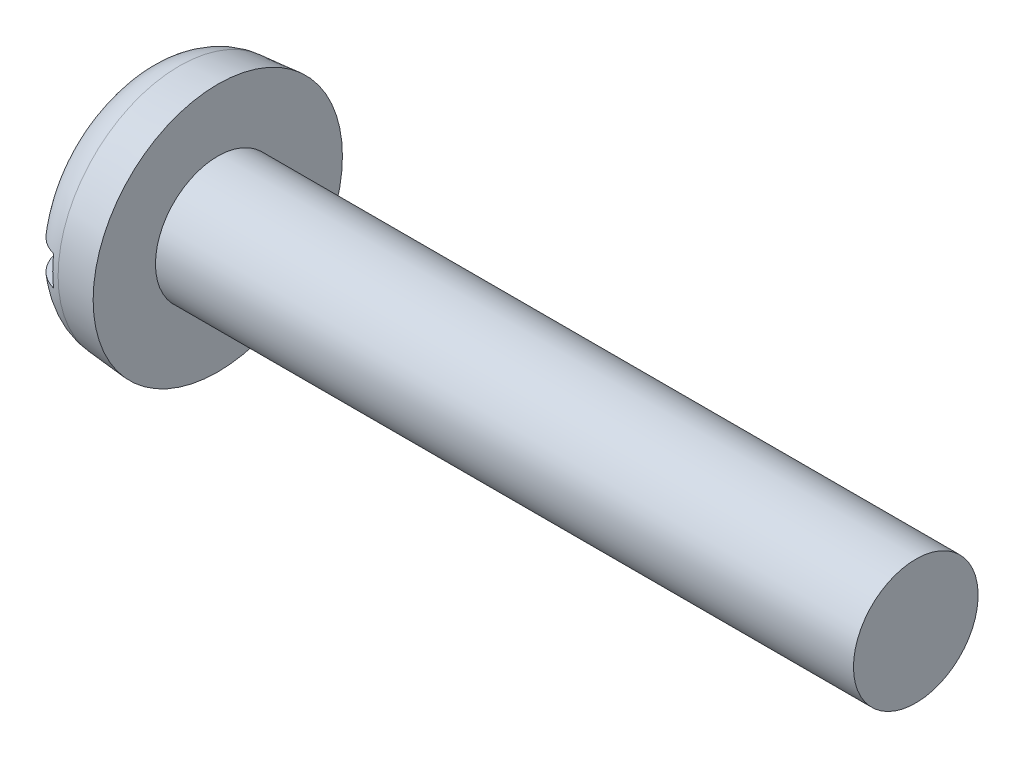
from build123d import *

# Parameters (mm, degrees)
FILLET2_R  = 0.8
SKETCH2_W  = 5
SKETCH2_H  = 0.6
SLOT_DEPTH = 0.6


with BuildPart() as part:
    # BodySke → Base-Revolve (revolve)
    with BuildSketch(Plane.XY):
        Polygon((1.5, 1.25), (1.5, 2.5), (0, 2.368767005), (0, 0), (15.5, 0), (15.5, 1.25), align=None)
    revolve(axis=Axis((-25.4, 0, 0), (1, 0, 0)))

    # Fillet2
    fillet2_edges = [part.edges().sort_by_distance(p)[0] for p in [
        (0, -2.368767005, 0),
    ]]
    fillet(fillet2_edges, radius=FILLET2_R)

    # Sketch2 → Slot (cut)
    with BuildSketch(Plane(origin=(0, 0, 0), x_dir=(0, 0, -1), z_dir=(1, 0, 0))):
        Rectangle(SKETCH2_W, SKETCH2_H)
    extrude(amount=SLOT_DEPTH, mode=Mode.SUBTRACT)


solid = part.part
